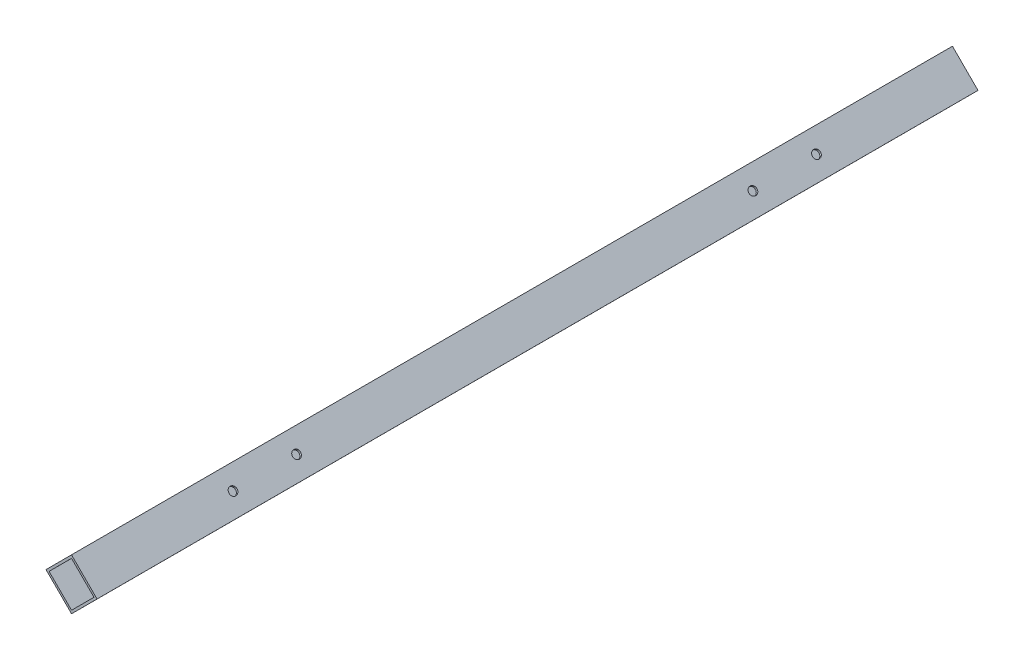
from build123d import *

# Parameters (mm, degrees)
EXTRUDE_1_DEPTH     = 610
SKETCH_2_R          = 2.75
CUT_EXTRUDE_1_DEPTH = 38.499979182


with BuildPart() as part:
    # 草圖1 → 填料-伸長1 (new body)
    with BuildSketch(Plane.XY):
        Polygon((0, 0), (17.69379362, -17.661530719), (0.032262901, -35.355324339), (-17.661530719, -17.69379362), align=None)
        Polygon((0.001935774, -2.12131946), (-15.540211259, -17.691857846), (0.030327127, -33.234004879), (15.57247416, -17.663466493), align=None, mode=Mode.SUBTRACT)
    extrude(amount=EXTRUDE_1_DEPTH)

    # 草圖2 → 除料-伸長1 (cut, through all)
    with BuildSketch(Plane(origin=(0, 0, 0), x_dir=(0.707751745, -0.706461229, 0), z_dir=(0.706461229, 0.707751745, 0))):
        with Locations((12.5, -463)):
            Circle(SKETCH_2_R)
        with Locations((12.5, -507)):
            Circle(SKETCH_2_R)
        with Locations((12.5, -103)):
            Circle(SKETCH_2_R)
        with Locations((12.5, -147)):
            Circle(SKETCH_2_R)
    extrude(amount=-CUT_EXTRUDE_1_DEPTH, mode=Mode.SUBTRACT)


solid = part.part
